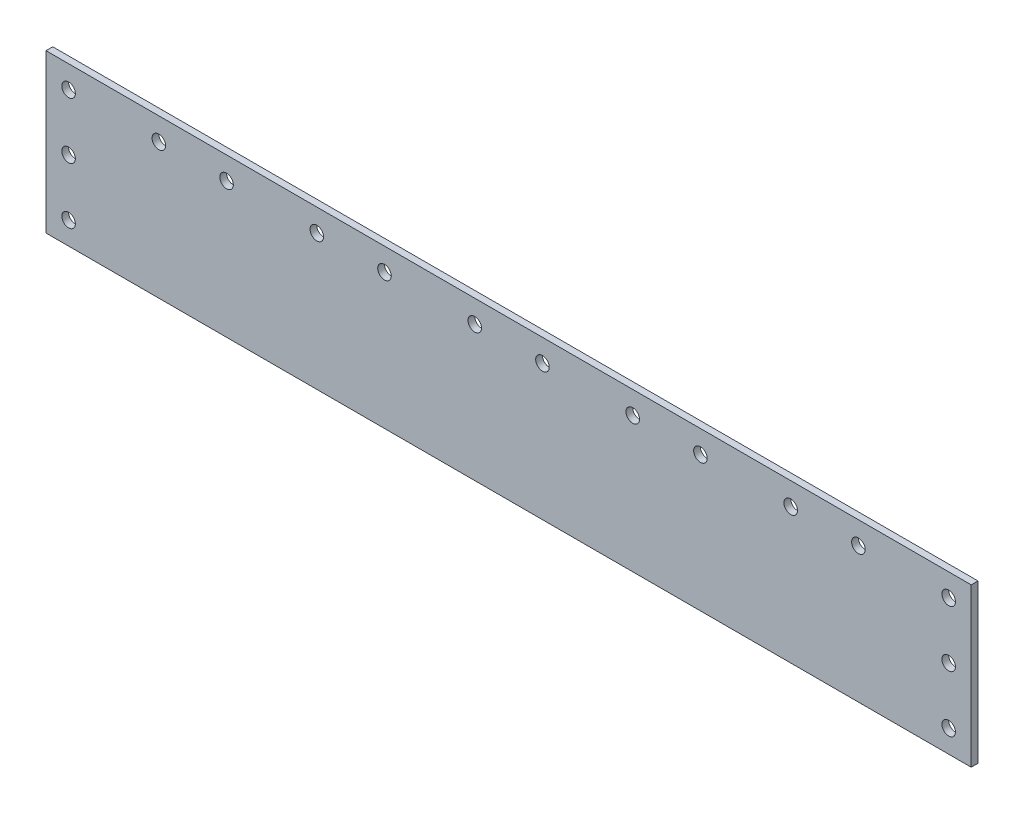
from build123d import *

# Parameters (mm, degrees)
SKETCH_1_W      = 410
SKETCH_1_H      = 70
SKETCH_1_R      = 3
EXTRUDE_1_DEPTH = 3


with BuildPart() as part:
    # 草图1 → 凸台-拉伸1 (new body)
    with BuildSketch(Plane.XY):
        with Locations((205, 35)):
            Rectangle(SKETCH_1_W, SKETCH_1_H)
        with Locations((10, 60)):
            Circle(SKETCH_1_R, mode=Mode.SUBTRACT)
        with Locations((50, 60)):
            Circle(SKETCH_1_R, mode=Mode.SUBTRACT)
        with Locations((80, 60)):
            Circle(SKETCH_1_R, mode=Mode.SUBTRACT)
        with Locations((120, 60)):
            Circle(SKETCH_1_R, mode=Mode.SUBTRACT)
        with Locations((150, 60)):
            Circle(SKETCH_1_R, mode=Mode.SUBTRACT)
        with Locations((190, 60)):
            Circle(SKETCH_1_R, mode=Mode.SUBTRACT)
        with Locations((220, 60)):
            Circle(SKETCH_1_R, mode=Mode.SUBTRACT)
        with Locations((260, 60)):
            Circle(SKETCH_1_R, mode=Mode.SUBTRACT)
        with Locations((290, 60)):
            Circle(SKETCH_1_R, mode=Mode.SUBTRACT)
        with Locations((330, 60)):
            Circle(SKETCH_1_R, mode=Mode.SUBTRACT)
        with Locations((360, 60)):
            Circle(SKETCH_1_R, mode=Mode.SUBTRACT)
        with Locations((400, 60)):
            Circle(SKETCH_1_R, mode=Mode.SUBTRACT)
        with Locations((400, 10)):
            Circle(SKETCH_1_R, mode=Mode.SUBTRACT)
        with Locations((10, 10)):
            Circle(SKETCH_1_R, mode=Mode.SUBTRACT)
        with Locations((400, 35)):
            Circle(SKETCH_1_R, mode=Mode.SUBTRACT)
        with Locations((10, 35)):
            Circle(SKETCH_1_R, mode=Mode.SUBTRACT)
    extrude(amount=EXTRUDE_1_DEPTH)


solid = part.part
